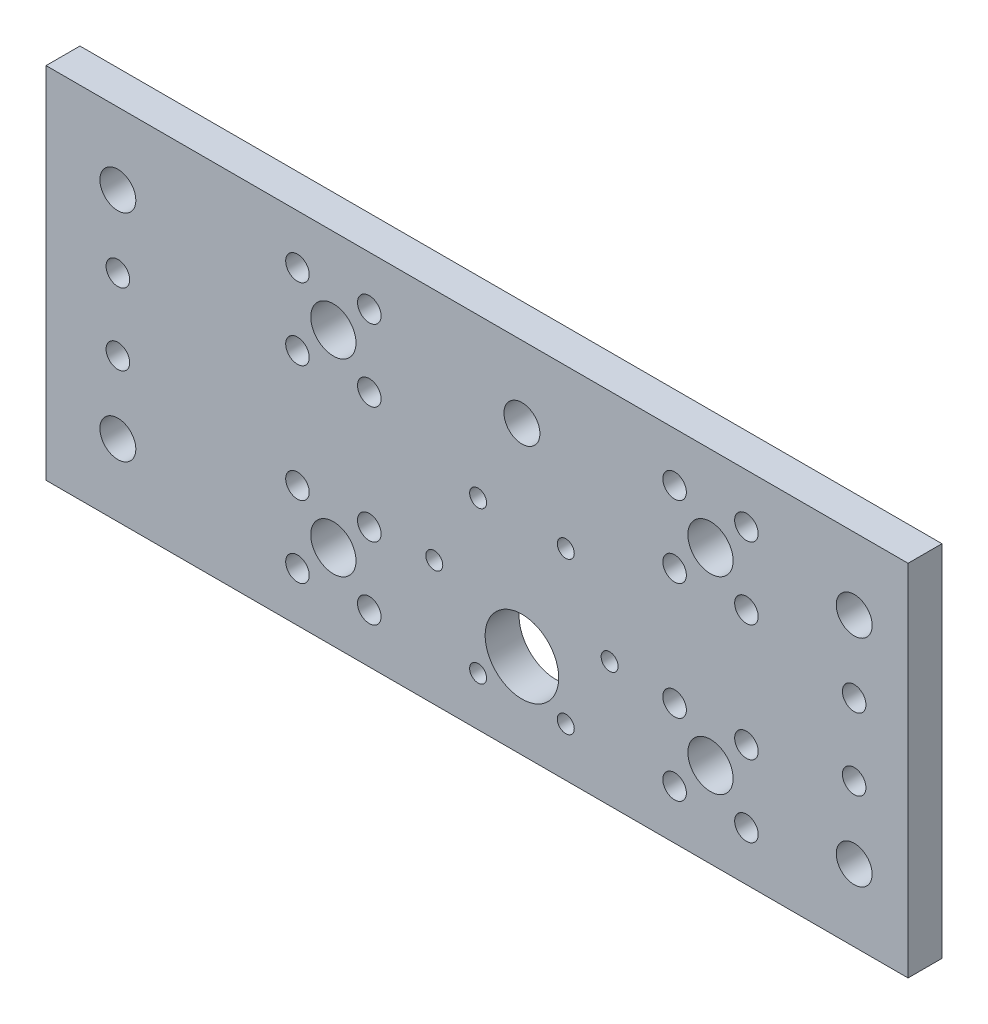
from build123d import *

# Parameters (mm, degrees)
SKETCH1_W           = 152.4
SKETCH1_H           = 63.5
SKETCH1_R           = 6.5
SKETCH1_R_2         = 1.5
SKETCH1_R_3         = 4
SKETCH1_R_4         = 3.175
SKETCH1_R_5         = 2.0828
BOSS_EXTRUDE1_DEPTH = 5.9944


with BuildPart() as part:
    # Sketch1 → Boss-Extrude1 (new body)
    with BuildSketch(Plane.XY):
        with Locations((76.2, 31.75)):
            Rectangle(SKETCH1_W, SKETCH1_H)
        with Locations((84.1375, 15.0749)):
            Circle(SKETCH1_R, mode=Mode.SUBTRACT)
        with Locations((68.6375, 22.0749)):
            Circle(SKETCH1_R_2, mode=Mode.SUBTRACT)
        with Locations((99.6375, 22.0749)):
            Circle(SKETCH1_R_2, mode=Mode.SUBTRACT)
        with Locations((91.8875, 8.651506241)):
            Circle(SKETCH1_R_2, mode=Mode.SUBTRACT)
        with Locations((76.3875, 8.651506241)):
            Circle(SKETCH1_R_2, mode=Mode.SUBTRACT)
        with Locations((76.3875, 35.498293759)):
            Circle(SKETCH1_R_2, mode=Mode.SUBTRACT)
        with Locations((91.8875, 35.498293759)):
            Circle(SKETCH1_R_2, mode=Mode.SUBTRACT)
        with Locations((50.8, 48.4251)):
            Circle(SKETCH1_R_3, mode=Mode.SUBTRACT)
        with Locations((12.7, 50.8)):
            Circle(SKETCH1_R_4, mode=Mode.SUBTRACT)
        with Locations((12.7, 12.7)):
            Circle(SKETCH1_R_4, mode=Mode.SUBTRACT)
        with Locations((117.475, 48.4251)):
            Circle(SKETCH1_R_3, mode=Mode.SUBTRACT)
        with Locations((117.475, 15.0749)):
            Circle(SKETCH1_R_3, mode=Mode.SUBTRACT)
        with Locations((50.8, 15.0749)):
            Circle(SKETCH1_R_3, mode=Mode.SUBTRACT)
        with Locations((44.45, 21.4249)):
            Circle(SKETCH1_R_5, mode=Mode.SUBTRACT)
        with Locations((44.45, 8.7249)):
            Circle(SKETCH1_R_5, mode=Mode.SUBTRACT)
        with Locations((57.15, 8.7249)):
            Circle(SKETCH1_R_5, mode=Mode.SUBTRACT)
        with Locations((57.15, 21.4249)):
            Circle(SKETCH1_R_5, mode=Mode.SUBTRACT)
        with Locations((44.45, 54.7751)):
            Circle(SKETCH1_R_5, mode=Mode.SUBTRACT)
        with Locations((44.45, 42.0751)):
            Circle(SKETCH1_R_5, mode=Mode.SUBTRACT)
        with Locations((57.15, 42.0751)):
            Circle(SKETCH1_R_5, mode=Mode.SUBTRACT)
        with Locations((57.15, 54.7751)):
            Circle(SKETCH1_R_5, mode=Mode.SUBTRACT)
        with Locations((111.125, 54.7751)):
            Circle(SKETCH1_R_5, mode=Mode.SUBTRACT)
        with Locations((111.125, 42.0751)):
            Circle(SKETCH1_R_5, mode=Mode.SUBTRACT)
        with Locations((123.825, 42.0751)):
            Circle(SKETCH1_R_5, mode=Mode.SUBTRACT)
        with Locations((123.825, 54.7751)):
            Circle(SKETCH1_R_5, mode=Mode.SUBTRACT)
        with Locations((142.875, 50.8)):
            Circle(SKETCH1_R_4, mode=Mode.SUBTRACT)
        with Locations((142.875, 12.7)):
            Circle(SKETCH1_R_4, mode=Mode.SUBTRACT)
        with Locations((84.1375, 50.8)):
            Circle(SKETCH1_R_4, mode=Mode.SUBTRACT)
        with Locations((12.7, 38.1)):
            Circle(SKETCH1_R_5, mode=Mode.SUBTRACT)
        with Locations((111.125, 21.4249)):
            Circle(SKETCH1_R_5, mode=Mode.SUBTRACT)
        with Locations((111.125, 8.7249)):
            Circle(SKETCH1_R_5, mode=Mode.SUBTRACT)
        with Locations((123.825, 8.7249)):
            Circle(SKETCH1_R_5, mode=Mode.SUBTRACT)
        with Locations((123.825, 21.4249)):
            Circle(SKETCH1_R_5, mode=Mode.SUBTRACT)
        with Locations((12.7, 25.4)):
            Circle(SKETCH1_R_5, mode=Mode.SUBTRACT)
        with Locations((142.875, 38.1)):
            Circle(SKETCH1_R_5, mode=Mode.SUBTRACT)
        with Locations((142.875, 25.4)):
            Circle(SKETCH1_R_5, mode=Mode.SUBTRACT)
    extrude(amount=BOSS_EXTRUDE1_DEPTH)


solid = part.part
